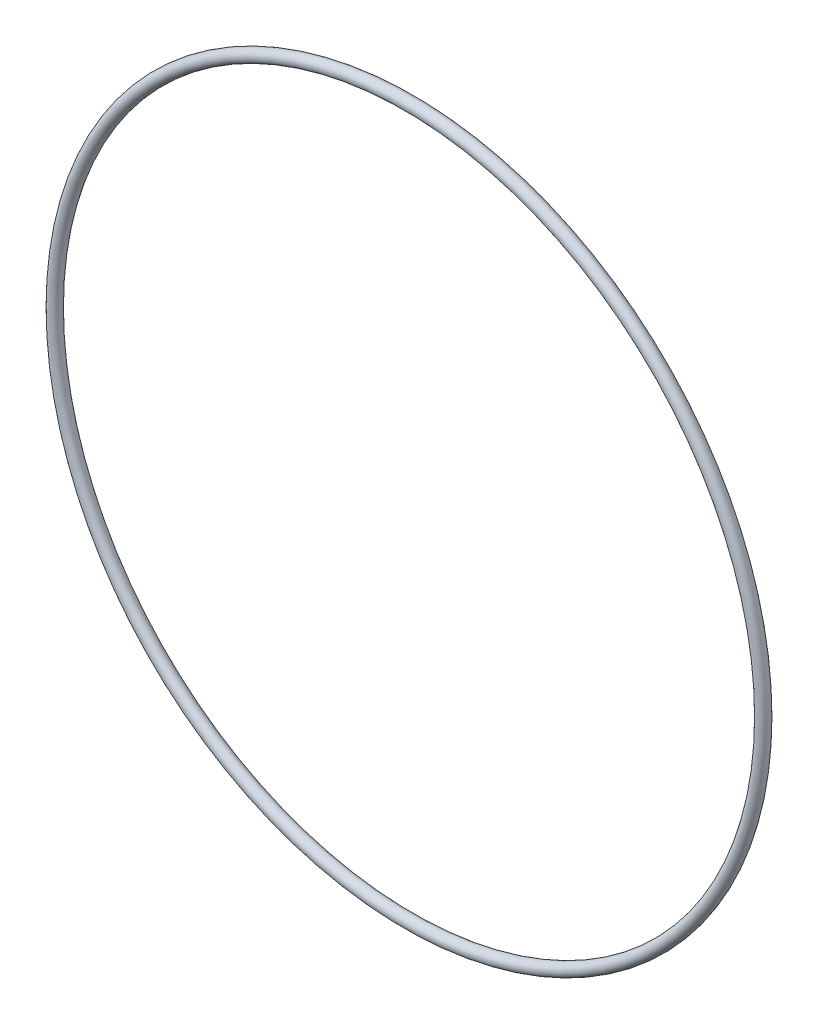
from build123d import *

# Parameters (mm, degrees)
SKETCH2_R = 1.5


with BuildPart() as part:
    # Sketch2 → Revolve1 (revolve)
    with BuildSketch(Plane(origin=(0, 0, 0), x_dir=(1, 0, 0), z_dir=(0, 1, 0))):
        with Locations((-86.5, 0)):
            Circle(SKETCH2_R)
    revolve(axis=Axis((0, 0, -1.65), (0, 0, 1)))


solid = part.part
